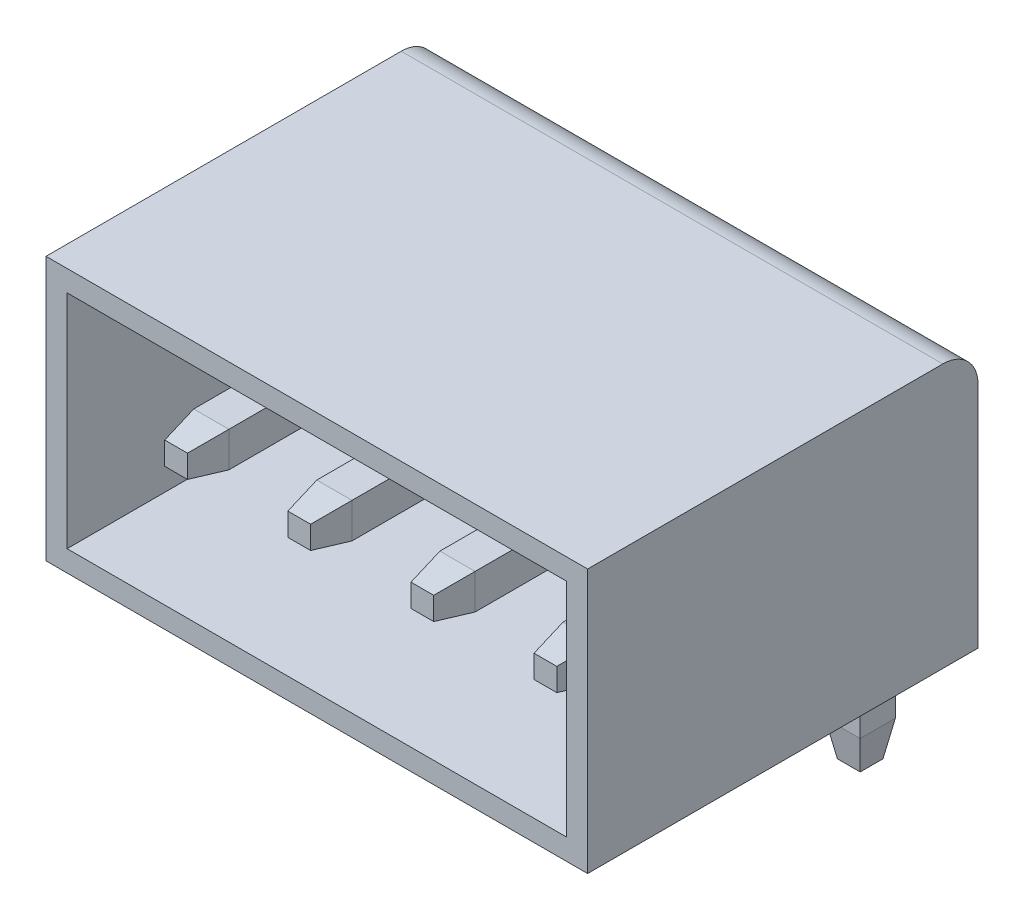
from build123d import *

# Parameters (mm, degrees)
SKETCH1_W                       = 11.1
SKETCH1_H                       = 7.5
MAIN_BASE_DEPTH                 = 15.4
FILLET1_R                       = 1
SKETCH7_W                       = 14.2
SKETCH7_H                       = 6.3
HOLE_DEPTH                      = 7.8
LEG_DEPTH                       = 0.5
LEG_BOTTOM_CHAMFER_SIZE         = 1
LEG_BOTTOM_CHAMFER_SIZE2        = 0.176326981
LEG_BOTTOM_CHAMFER_PART_2_SIZE  = 1
LEG_BOTTOM_CHAMFER_PART_2_SIZE2 = 0.176326981
LEG_BOTTOM_CHAMFER_PART_3_SIZE  = 1
LEG_BOTTOM_CHAMFER_PART_3_SIZE2 = 0.176326981
LEG_BOTTOM_CHAMFER_PART_4_SIZE  = 1
LEG_BOTTOM_CHAMFER_PART_4_SIZE2 = 0.176326981
LEG_UPPER_CHAMFER_SIZE          = 1
LEG_UPPER_CHAMFER_SIZE2         = 0.176326981
LEG_UPPER_CHAMFER_PART_2_SIZE   = 1
LEG_UPPER_CHAMFER_PART_2_SIZE2  = 0.176326981
LEG_UPPER_CHAMFER_PART_3_SIZE   = 1
LEG_UPPER_CHAMFER_PART_3_SIZE2  = 0.176326981
LEG_UPPER_CHAMFER_PART_4_SIZE   = 1
LEG_UPPER_CHAMFER_PART_4_SIZE2  = 0.176326981
F_4_LEG_PATTERN_COUNT           = 4
F_4_LEG_PATTERN_PITCH           = 3.5


with BuildPart() as part:
    # Sketch1 → Main Base (new body)
    with BuildSketch(Plane(origin=(0, 0, 0), x_dir=(0, 0, -1), z_dir=(1, 0, 0))):
        with Locations((5.55, 3.75)):
            Rectangle(SKETCH1_W, SKETCH1_H)
    extrude(amount=MAIN_BASE_DEPTH)

    # Fillet1
    fillet1_edges = [part.edges().sort_by_distance(p)[0] for p in [
        (7.7, 7.5, -11.1),
    ]]
    fillet(fillet1_edges, radius=FILLET1_R)

    # Sketch7 → Hole (cut)
    with BuildSketch(Plane.XY):
        with Locations((7.7, 3.75)):
            Rectangle(SKETCH7_W, SKETCH7_H)
    extrude(amount=-HOLE_DEPTH, mode=Mode.SUBTRACT)


with BuildPart() as body_2:
    # Sketch2 → Leg (new body, symmetric)
    with BuildSketch(Plane(origin=(12.95, 0, 0), x_dir=(0, 0, -1), z_dir=(1, 0, 0))):
        with BuildLine():
            Line((1.25, 3.590534207), (1.25, 2.590534207))
            Line((1.25, 2.590534207), (8.7, 2.590534207))
            ThreePointArc((8.7, 2.590534207), (9.407106781, 2.297640988), (9.7, 1.590534207))
            Line((9.7, 1.590534207), (9.7, -3.5))
            Line((9.7, -3.5), (10.7, -3.5))
            Line((10.7, -3.5), (10.7, 1.790534207))
            ThreePointArc((10.7, 1.790534207), (10.172792206, 3.063326413), (8.9, 3.590534207))
            Line((8.9, 3.590534207), (1.25, 3.590534207))
        make_face()
    extrude(amount=LEG_DEPTH, both=True)

    # Leg Bottom Chamfer
    leg_bottom_chamfer_edges = [body_2.edges().sort_by_distance(p)[0] for p in [
        (12.95, -3.5, -10.7),
    ]]
    leg_bottom_chamfer_side = [body_2.faces().sort_by_distance(p)[0] for p in [
        (12.95, -0.854732897, -10.7),
    ]]
    chamfer(leg_bottom_chamfer_edges, length=LEG_BOTTOM_CHAMFER_SIZE, length2=LEG_BOTTOM_CHAMFER_SIZE2, reference=leg_bottom_chamfer_side[0])

    # Leg Bottom Chamfer part 2
    leg_bottom_chamfer_part_2_edges = [body_2.edges().sort_by_distance(p)[0] for p in [
        (12.95, -3.5, -9.7),
    ]]
    leg_bottom_chamfer_part_2_side = [body_2.faces().sort_by_distance(p)[0] for p in [
        (12.95, -0.954732897, -9.7),
    ]]
    chamfer(leg_bottom_chamfer_part_2_edges, length=LEG_BOTTOM_CHAMFER_PART_2_SIZE, length2=LEG_BOTTOM_CHAMFER_PART_2_SIZE2, reference=leg_bottom_chamfer_part_2_side[0])

    # Leg Bottom Chamfer part 3
    leg_bottom_chamfer_part_3_edges = [body_2.edges().sort_by_distance(p)[0] for p in [
        (13.45, -3.5, -10.2),
    ]]
    leg_bottom_chamfer_part_3_side = [body_2.faces().sort_by_distance(p)[0] for p in [
        (13.45, 3.472390999, -5.075),
    ]]
    chamfer(leg_bottom_chamfer_part_3_edges, length=LEG_BOTTOM_CHAMFER_PART_3_SIZE, length2=LEG_BOTTOM_CHAMFER_PART_3_SIZE2, reference=leg_bottom_chamfer_part_3_side[0])

    # Leg Bottom Chamfer part 4
    leg_bottom_chamfer_part_4_edges = [body_2.edges().sort_by_distance(p)[0] for p in [
        (12.45, -3.5, -10.2),
    ]]
    leg_bottom_chamfer_part_4_side = [body_2.faces().sort_by_distance(p)[0] for p in [
        (12.45, 3.472390999, -5.075),
    ]]
    chamfer(leg_bottom_chamfer_part_4_edges, length=LEG_BOTTOM_CHAMFER_PART_4_SIZE, length2=LEG_BOTTOM_CHAMFER_PART_4_SIZE2, reference=leg_bottom_chamfer_part_4_side[0])

    # Leg Upper Chamfer
    leg_upper_chamfer_edges = [body_2.edges().sort_by_distance(p)[0] for p in [
        (12.45, 3.090534207, -1.25),
    ]]
    leg_upper_chamfer_side = [body_2.faces().sort_by_distance(p)[0] for p in [
        (12.45, -2.387573532, -10.2),
    ]]
    chamfer(leg_upper_chamfer_edges, length=LEG_UPPER_CHAMFER_SIZE, length2=LEG_UPPER_CHAMFER_SIZE2, reference=leg_upper_chamfer_side[0])

    # Leg Upper Chamfer part 2
    leg_upper_chamfer_part_2_edges = [body_2.edges().sort_by_distance(p)[0] for p in [
        (12.95, 2.590534207, -1.25),
    ]]
    leg_upper_chamfer_part_2_side = [body_2.faces().sort_by_distance(p)[0] for p in [
        (12.95, 2.590534207, -4.975),
    ]]
    chamfer(leg_upper_chamfer_part_2_edges, length=LEG_UPPER_CHAMFER_PART_2_SIZE, length2=LEG_UPPER_CHAMFER_PART_2_SIZE2, reference=leg_upper_chamfer_part_2_side[0])

    # Leg Upper Chamfer part 3
    leg_upper_chamfer_part_3_edges = [body_2.edges().sort_by_distance(p)[0] for p in [
        (12.95, 3.590534207, -1.25),
    ]]
    leg_upper_chamfer_part_3_side = [body_2.faces().sort_by_distance(p)[0] for p in [
        (12.95, 3.590534207, -5.075),
    ]]
    chamfer(leg_upper_chamfer_part_3_edges, length=LEG_UPPER_CHAMFER_PART_3_SIZE, length2=LEG_UPPER_CHAMFER_PART_3_SIZE2, reference=leg_upper_chamfer_part_3_side[0])

    # Leg Upper Chamfer part 4
    leg_upper_chamfer_part_4_edges = [body_2.edges().sort_by_distance(p)[0] for p in [
        (13.45, 3.090534207, -1.25),
    ]]
    leg_upper_chamfer_part_4_side = [body_2.faces().sort_by_distance(p)[0] for p in [
        (13.45, -2.387573532, -10.2),
    ]]
    chamfer(leg_upper_chamfer_part_4_edges, length=LEG_UPPER_CHAMFER_PART_4_SIZE, length2=LEG_UPPER_CHAMFER_PART_4_SIZE2, reference=leg_upper_chamfer_part_4_side[0])


with BuildPart() as f_4_leg_pattern_1:
    # 4 Leg Pattern: pattern copy
    add(body_2.part.moved(Location(Vector(-1, 0, 0) * (1 * F_4_LEG_PATTERN_PITCH))))


with BuildPart() as f_4_leg_pattern_2:
    # 4 Leg Pattern: pattern copy
    add(body_2.part.moved(Location(Vector(-1, 0, 0) * (2 * F_4_LEG_PATTERN_PITCH))))


with BuildPart() as f_4_leg_pattern_3:
    # 4 Leg Pattern: pattern copy
    add(body_2.part.moved(Location(Vector(-1, 0, 0) * (3 * F_4_LEG_PATTERN_PITCH))))


solid = Compound([part.part, body_2.part, f_4_leg_pattern_1.part, f_4_leg_pattern_2.part, f_4_leg_pattern_3.part])
